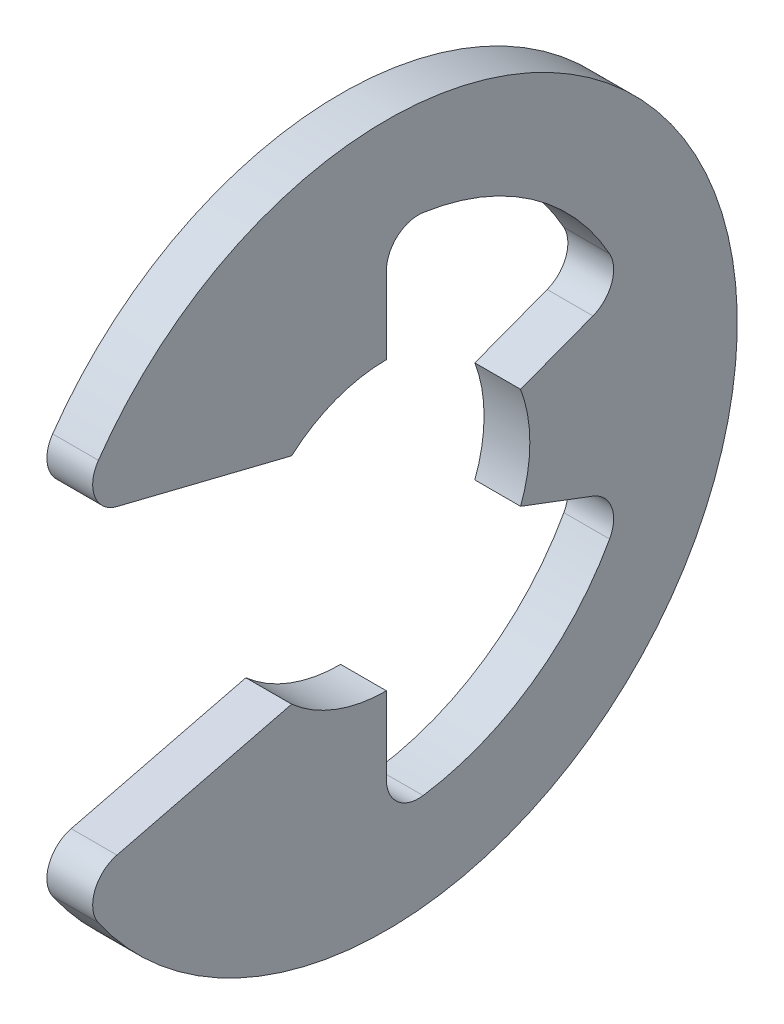
from build123d import *

# Parameters (mm, degrees)
EXTRUDE1_DEPTH = 0.1905
FILLET1_R      = 0.2667


with BuildPart() as part:
    # Sketch1 → Extrude1 (new body, symmetric)
    with BuildSketch(Plane(origin=(0, 0, 0), x_dir=(0, 0, -1), z_dir=(1, 0, 0))):
        with BuildLine():
            Line((-2.593812453, -1.343271365), (-0.789624479, -0.89535))
            ThreePointArc((-0.789624479, -0.89535), (-0.422072038, -1.116697647), (0, -1.1938))
            Line((0, -1.1938), (0, -2.123767742))
            ThreePointArc((0, -2.123767742), (1.207419966, -1.74714809), (1.986602815, -0.750865286))
            Line((1.986602815, -0.750865286), (1.116697647, -0.422072038))
            ThreePointArc((1.116697647, -0.422072038), (1.1938, 0), (1.116697647, 0.422072038))
            Line((1.116697647, 0.422072038), (1.986602815, 0.750865286))
            ThreePointArc((1.986602815, 0.750865286), (1.207419966, 1.74714809), (0, 2.123767742))
            Line((0, 2.123767742), (0, 1.1938))
            ThreePointArc((0, 1.1938), (-0.422072038, 1.116697647), (-0.789624479, 0.89535))
            Line((-0.789624479, 0.89535), (-2.593812453, 1.343271365))
            ThreePointArc((-2.593812453, 1.343271365), (2.921, 0), (-2.593812453, -1.343271365))
        make_face()
    extrude(amount=EXTRUDE1_DEPTH, both=True)

    # Fillet1
    fillet1_edges = [part.edges().sort_by_distance(p)[0] for p in [
        (0, -1.343271365, 2.593812453),
        (0, -2.123767742, 0),
        (0, -0.750865286, -1.986602815),
        (0, 0.750865286, -1.986602815),
        (0, 2.123767742, 0),
        (0, 1.343271365, 2.593812453),
    ]]
    fillet(fillet1_edges, radius=FILLET1_R)


solid = part.part
